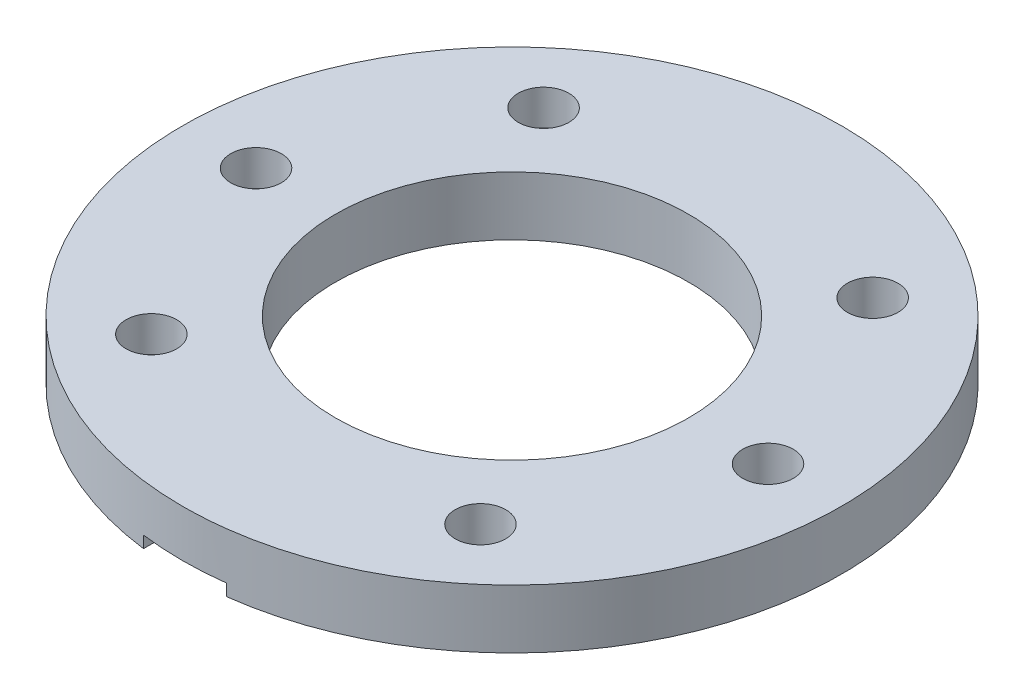
from build123d import *

# Parameters (mm, degrees)
SKETCH_1_R          = 28
SKETCH_1_R_2        = 2.15
SKETCH_1_R_3        = 15
EXTRUDE_1_DEPTH     = 5
CUT_EXTRUDE_3_DEPTH = 1
SKETCH_5_R          = 5
CUT_EXTRUDE_5_DEPTH = 2
SKETCH_6_R          = 4.5
CUT_EXTRUDE_6_DEPTH = 1


with BuildPart() as part:
    # 草图1 → 凸台-拉伸1 (new body)
    with BuildSketch(Plane(origin=(0, 0, 0), x_dir=(1, 0, 0), z_dir=(0, 1, 0))):
        Circle(SKETCH_1_R)
        with Locations((13.980630511, -16.661466638)):
            Circle(SKETCH_1_R_2, mode=Mode.SUBTRACT)
        with Locations((13.980630511, 16.661466638)):
            Circle(SKETCH_1_R_2, mode=Mode.SUBTRACT)
        with Locations((21.75, 0)):
            Circle(SKETCH_1_R_2, mode=Mode.SUBTRACT)
        with Locations((-13.980630511, -16.661466638)):
            Circle(SKETCH_1_R_2, mode=Mode.SUBTRACT)
        with Locations((-21.75, 0)):
            Circle(SKETCH_1_R_2, mode=Mode.SUBTRACT)
        with Locations((-13.980630511, 16.661466638)):
            Circle(SKETCH_1_R_2, mode=Mode.SUBTRACT)
        Circle(SKETCH_1_R_3, mode=Mode.SUBTRACT)
    extrude(amount=EXTRUDE_1_DEPTH)

    # 草图2 → 切除-拉伸3 (cut)
    with BuildSketch(Plane(origin=(0, 0, 0), x_dir=(1, 0, 0), z_dir=(0, 1, 0))):
        with BuildLine():
            Line((3.535533906, -26.535533906), (3.535533906, -27.775888825))
            ThreePointArc((3.535533906, -27.775888825), (0, -28), (-3.535533906, -27.775888825))
            Line((-3.535533906, -27.775888825), (-3.535533906, -26.535533906))
            ThreePointArc((-3.535533906, -26.535533906), (0, -18), (3.535533906, -26.535533906))
        make_face()
    extrude(amount=CUT_EXTRUDE_3_DEPTH, mode=Mode.SUBTRACT)

    # 草图5 → 切除-拉伸5 (cut)
    with BuildSketch(Plane.XZ):
        with Locations((-13.980630511, 16.661466638)):
            Circle(SKETCH_5_R)
        with Locations((-21.75, 0)):
            Circle(SKETCH_5_R)
        with Locations((-13.980630511, -16.661466638)):
            Circle(SKETCH_5_R)
    extrude(amount=-CUT_EXTRUDE_5_DEPTH, mode=Mode.SUBTRACT)

    # 草图6 → 切除-拉伸6 (cut)
    with BuildSketch(Plane.XZ.offset(-1)):
        with Locations((0, 23)):
            Circle(SKETCH_6_R)
    extrude(amount=-CUT_EXTRUDE_6_DEPTH, mode=Mode.SUBTRACT)

    # 草图7 → 旋转1 (revolve)
    with BuildSketch(Plane(origin=(0, 0, 0), x_dir=(0, -1, 0), z_dir=(-1, 0, 0))):
        Polygon((-2, 23), (-1, 23), (-2, 27.5), align=None)
    revolve(axis=Axis((0, 2, 23), (0, -1, 0)))


solid = part.part
